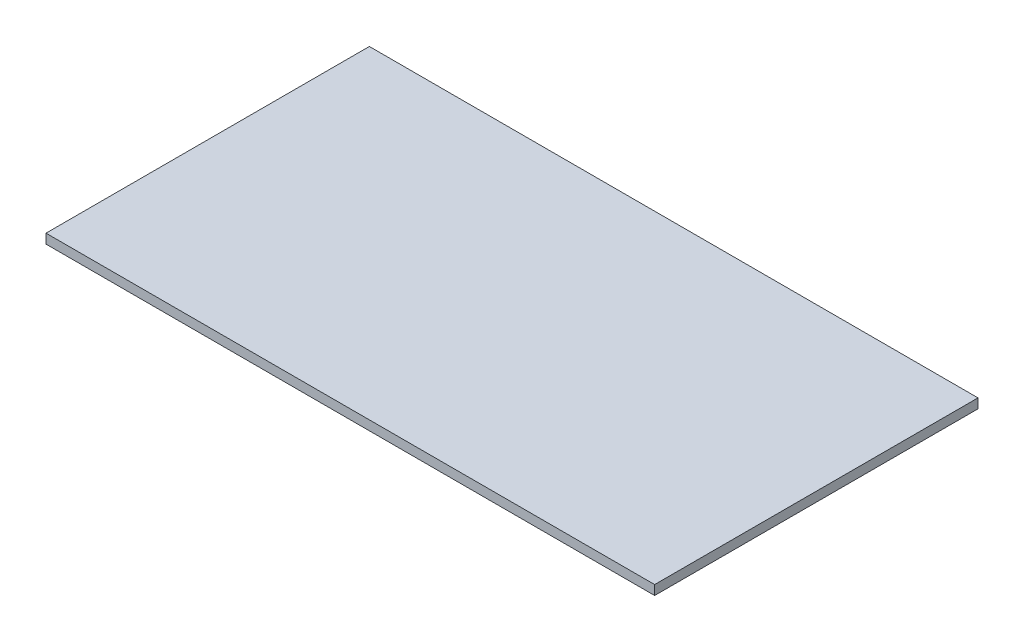
from build123d import *

# Parameters (mm, degrees)
SKETCH1_W           = 960
SKETCH1_H           = 510
BOSS_EXTRUDE1_DEPTH = 7.5


with BuildPart() as part:
    # Sketch1 → Boss-Extrude1 (new body, symmetric)
    with BuildSketch(Plane(origin=(0, 0, 0), x_dir=(1, 0, 0), z_dir=(0, 1, 0))):
        Rectangle(SKETCH1_W, SKETCH1_H)
    extrude(amount=BOSS_EXTRUDE1_DEPTH, both=True)


solid = part.part
